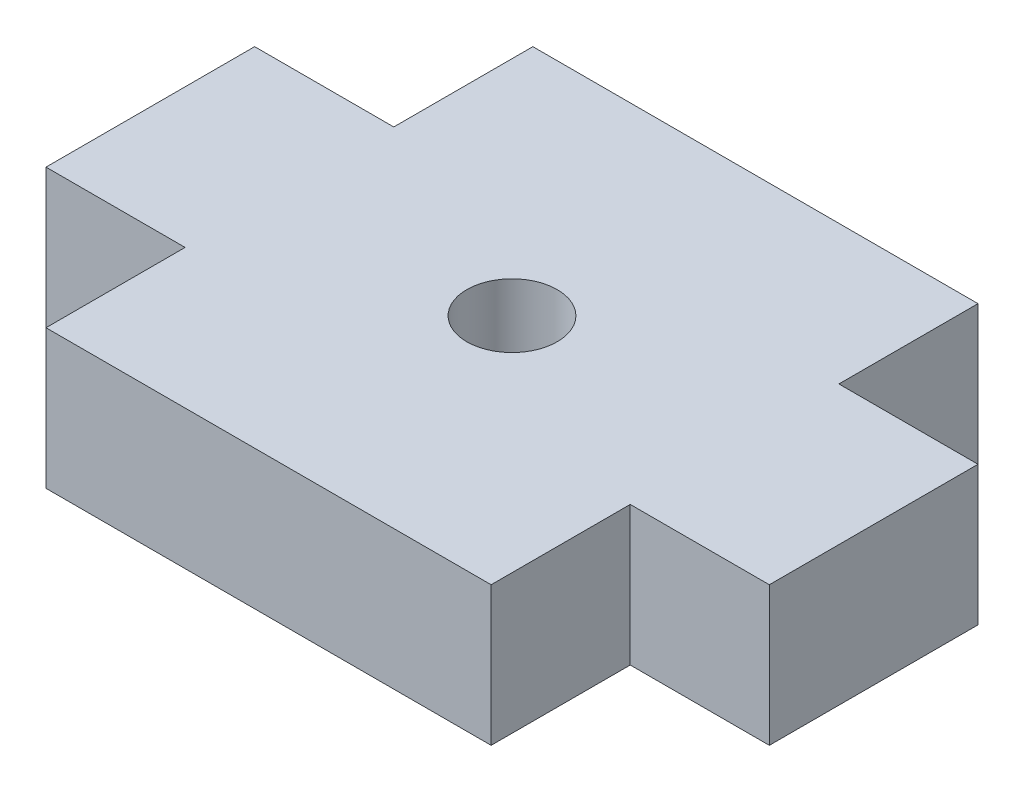
from build123d import *

# Parameters (mm, degrees)
SKETCH1_R           = 1.625
BOSS_EXTRUDE1_DEPTH = 5


with BuildPart() as part:
    # Sketch1 → Boss-Extrude1 (new body)
    with BuildSketch(Plane(origin=(0, 0, 0), x_dir=(1, 0, 0), z_dir=(0, 1, 0))):
        Polygon((-8, 8.75), (8, 8.75), (8, 3.75), (13, 3.75), (13, -3.75), (8, -3.75), (8, -8.75), (-8, -8.75), (-8, -3.75), (-13, -3.75), (-13, 3.75), (-8, 3.75), align=None)
        Circle(SKETCH1_R, mode=Mode.SUBTRACT)
    extrude(amount=BOSS_EXTRUDE1_DEPTH)


solid = part.part
